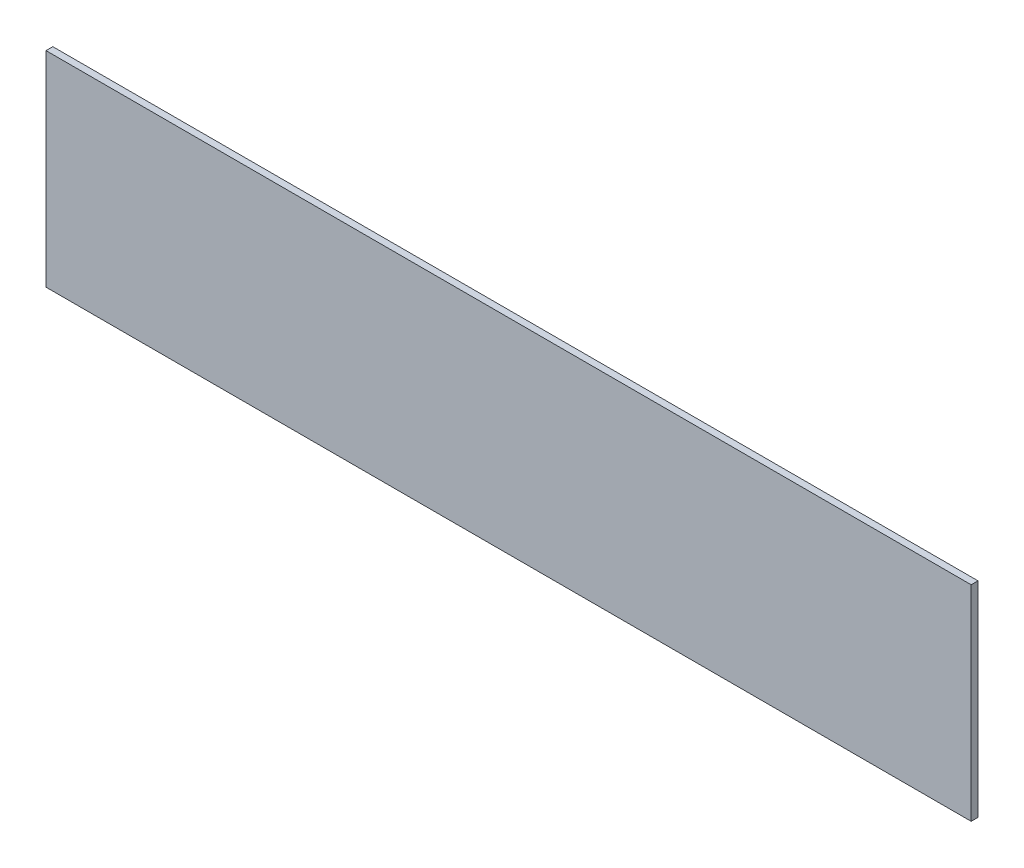
from build123d import *

# Parameters (mm, degrees)
SKETCH1_W           = 203.2
SKETCH1_H           = 45
BOSS_EXTRUDE1_DEPTH = 1.5


with BuildPart() as part:
    # Sketch1 → Boss-Extrude1 (new body)
    with BuildSketch(Plane.XY):
        Rectangle(SKETCH1_W, SKETCH1_H)
    extrude(amount=BOSS_EXTRUDE1_DEPTH)


solid = part.part
